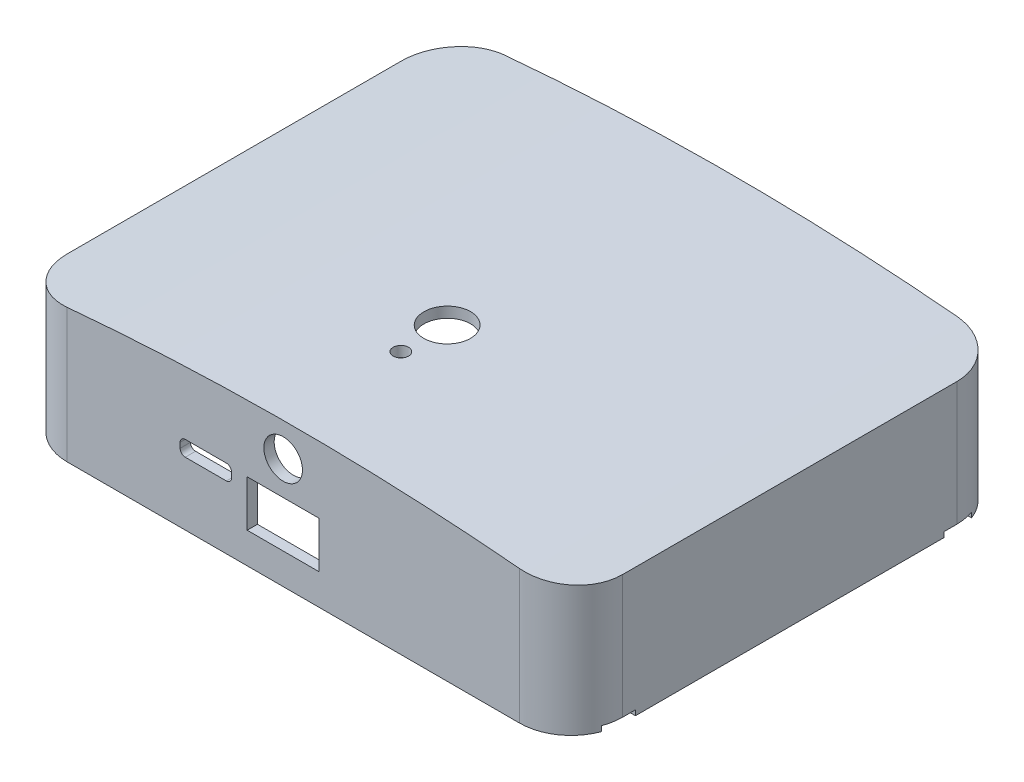
from build123d import *

# Parameters (mm, degrees)
BOSS_EXTRUDE5_DEPTH = 42
CUT_EXTRUDE6_DEPTH  = 95
BOSS_EXTRUDE8_DEPTH = 85
CUT_EXTRUDE7_DEPTH  = 85
SKETCH26_W          = 14
SKETCH26_H          = 9
SKETCH26_R          = 3.75
CUT_EXTRUDE9_DEPTH  = 15
BOSS_EXTRUDE9_DEPTH = 15
CUT_EXTRUDE11_DEPTH = 1
SKETCH30_R          = 1.4
CUT_EXTRUDE12_DEPTH = 15
CUT_EXTRUDE17_DEPTH = 3
SKETCH32_R          = 4.528419636
CUT_EXTRUDE18_DEPTH = 42
SKETCH33_R          = 1.5
CUT_EXTRUDE19_DEPTH = 42
CUT_EXTRUDE20_DEPTH = 3


with BuildPart() as part:
    # Sketch10 → Boss-Extrude5 (new body)
    with BuildSketch(Plane(origin=(0, 2, 0), x_dir=(1, 0, 0), z_dir=(0, 1, 0))):
        with BuildLine():
            Line((67.998956535, 10), (67.998956535, 75))
            ThreePointArc((67.998956535, 75), (65.070024347, 82.071067812), (57.998956535, 85))
            Line((57.998956535, 85), (-30.001043465, 85))
            ThreePointArc((-30.001043465, 85), (-37.072111277, 82.071067812), (-40.001043465, 75))
            Line((-40.001043465, 75), (-40.001043465, 10))
            ThreePointArc((-40.001043465, 10), (-37.072111277, 2.928932188), (-30.001043465, 0))
            Line((-30.001043465, 0), (57.998956535, 0))
            ThreePointArc((57.998956535, 0), (65.070024347, 2.928932188), (67.998956535, 10))
        make_face()
        with BuildLine():
            Line((57.998956535, 83), (-30.001043465, 83))
            ThreePointArc((-30.001043465, 83), (-35.657897714, 80.656854249), (-38.001043465, 75))
            Line((-38.001043465, 75), (-38.001043465, 10))
            ThreePointArc((-38.001043465, 10), (-35.657897714, 4.343145751), (-30.001043465, 2))
            Line((-30.001043465, 2), (57.998956535, 2))
            ThreePointArc((57.998956535, 2), (63.655810785, 4.343145751), (65.998956535, 10))
            Line((65.998956535, 10), (65.998956535, 75))
            ThreePointArc((65.998956535, 75), (63.655810785, 80.656854249), (57.998956535, 83))
        make_face(mode=Mode.SUBTRACT)
    extrude(amount=BOSS_EXTRUDE5_DEPTH)

    # Sketch22 → Cut-Extrude6 (cut)
    with BuildSketch(Plane.XY):
        with BuildLine():
            Line((67.998956535, 44), (67.998956535, 25))
            add(Edge.make_bspline(
                [(-40.001043465, 25), (13.998956535, 31.099161407), (67.998956535, 25)],
                knots=[0, 0, 0, 1, 1, 1], degree=2))
            Line((-40.001043465, 25), (-40.001043465, 44))
            Line((-40.001043465, 44), (-30.001043465, 44))
            Line((-30.001043465, 44), (57.998956535, 44))
            Line((57.998956535, 44), (67.998956535, 44))
        make_face()
    extrude(amount=-CUT_EXTRUDE6_DEPTH, mode=Mode.SUBTRACT)

    # Sketch20 → Boss-Extrude8 (add)
    with BuildSketch(Plane.XY):
        with BuildLine():
            Line((-40.001043465, 25), (-40.001043465, 27.029988546))
            add(Edge.make_bspline(
                [(67.998956535, 27.029988546), (13.998956535, 32.999215936), (-40.001043465, 27.029988546)],
                knots=[0, 0, 0, 1, 1, 1], degree=2))
            Line((67.998956535, 27.029988546), (67.998956535, 25))
            add(Edge.make_bspline(
                [(-40.001043465, 25), (13.998956535, 30.916770486), (67.998956535, 25)],
                knots=[0, 0, 0, 1, 1, 1], degree=2))
        make_face()
    extrude(amount=-BOSS_EXTRUDE8_DEPTH)

    # Sketch23 → Cut-Extrude7 (cut)
    with BuildSketch(Plane.XZ.offset(-2)):
        with BuildLine():
            Line((-40.001043465, -75), (-40.001043465, -85))
            Line((-40.001043465, -85), (-30.001043465, -85))
            ThreePointArc((-30.001043465, -85), (-37.072111277, -82.071067812), (-40.001043465, -75))
        make_face()
        with BuildLine():
            Line((57.998956535, -85), (67.998956535, -85))
            Line((67.998956535, -85), (67.998956535, -75))
            ThreePointArc((67.998956535, -75), (65.070024347, -82.071067812), (57.998956535, -85))
        make_face()
        with BuildLine():
            Line((67.998956535, -10), (67.998956535, 0))
            Line((67.998956535, 0), (57.998956535, 0))
            ThreePointArc((57.998956535, 0), (65.070024347, -2.928932188), (67.998956535, -10))
        make_face()
        with BuildLine():
            Line((-30.001043465, 0), (-40.001043465, 0))
            Line((-40.001043465, 0), (-40.001043465, -10))
            ThreePointArc((-40.001043465, -10), (-37.072111277, -2.928932188), (-30.001043465, 0))
        make_face()
    extrude(amount=-CUT_EXTRUDE7_DEPTH, mode=Mode.SUBTRACT)

    # Sketch26 → Cut-Extrude9 (cut)
    with BuildSketch(Plane.XY):
        with Locations((11.998956535, 12.5)):
            Rectangle(SKETCH26_W, SKETCH26_H)
        with Locations((11.998956535, 23.5)):
            Circle(SKETCH26_R)
    extrude(amount=-CUT_EXTRUDE9_DEPTH, mode=Mode.SUBTRACT)

    # Sketch28 → Boss-Extrude9 (add)
    with BuildSketch(Plane.XZ.offset(-2)):
        with BuildLine():
            Line((67.998956535, -75), (67.998956535, -72.5))
            Line((67.998956535, -72.5), (63.998956535, -72.5))
            ThreePointArc((63.998956535, -72.5), (60.998956535, -75.5), (63.998956535, -78.5))
            Line((63.998956535, -78.5), (67.366453533, -78.5))
            ThreePointArc((67.366453533, -78.5), (67.839560429, -76.778346145), (67.998956535, -75))
        make_face()
        with BuildLine():
            Line((-40.001043465, -10), (-40.001043465, -12.5))
            Line((-40.001043465, -12.5), (-36.001043465, -12.5))
            ThreePointArc((-36.001043465, -12.5), (-33.001043465, -9.5), (-36.001043465, -6.5))
            Line((-36.001043465, -6.5), (-39.368540462, -6.5))
            ThreePointArc((-39.368540462, -6.5), (-39.841647358, -8.221653855), (-40.001043465, -10))
        make_face()
        with BuildLine():
            Line((63.998956535, -12.5), (67.998956535, -12.5))
            Line((67.998956535, -12.5), (67.998956535, -10))
            ThreePointArc((67.998956535, -10), (67.839560429, -8.221653855), (67.366453533, -6.5))
            Line((67.366453533, -6.5), (63.998956535, -6.5))
            ThreePointArc((63.998956535, -6.5), (60.998956535, -9.5), (63.998956535, -12.5))
        make_face()
        with BuildLine():
            Line((-40.001043465, -72.5), (-40.001043465, -75))
            ThreePointArc((-40.001043465, -75), (-39.841647358, -76.778346145), (-39.368540462, -78.5))
            Line((-39.368540462, -78.5), (-36.001043465, -78.5))
            ThreePointArc((-36.001043465, -78.5), (-33.001043465, -75.5), (-36.001043465, -72.5))
            Line((-36.001043465, -72.5), (-40.001043465, -72.5))
        make_face()
    extrude(amount=-BOSS_EXTRUDE9_DEPTH)

    # Sketch29 → Cut-Extrude11 (cut)
    with BuildSketch(Plane.XZ.offset(-2)):
        with BuildLine():
            Line((67.998956535, -72.5), (67.998956535, -75))
            ThreePointArc((67.998956535, -75), (67.839560429, -76.778346145), (67.366453533, -78.5))
            Line((67.366453533, -78.5), (63.998956535, -78.5))
            ThreePointArc((63.998956535, -78.5), (60.998956535, -75.5), (63.998956535, -72.5))
            Line((63.998956535, -72.5), (67.998956535, -72.5))
        make_face()
        with BuildLine():
            Line((63.998956535, -12.5), (67.998956535, -12.5))
            Line((67.998956535, -12.5), (67.998956535, -10))
            ThreePointArc((67.998956535, -10), (67.839560429, -8.221653855), (67.366453533, -6.5))
            Line((67.366453533, -6.5), (63.998956535, -6.5))
            ThreePointArc((63.998956535, -6.5), (60.998956535, -9.5), (63.998956535, -12.5))
        make_face()
        with BuildLine():
            Line((-40.001043465, -12.5), (-40.001043465, -10))
            ThreePointArc((-40.001043465, -10), (-39.841647358, -8.221653855), (-39.368540462, -6.5))
            Line((-39.368540462, -6.5), (-36.001043465, -6.5))
            ThreePointArc((-36.001043465, -6.5), (-33.001043465, -9.5), (-36.001043465, -12.5))
            Line((-36.001043465, -12.5), (-40.001043465, -12.5))
        make_face()
        with BuildLine():
            Line((-39.368540462, -78.5), (-36.001043465, -78.5))
            ThreePointArc((-36.001043465, -78.5), (-33.001043465, -75.5), (-36.001043465, -72.5))
            Line((-36.001043465, -72.5), (-40.001043465, -72.5))
            Line((-40.001043465, -72.5), (-40.001043465, -75))
            ThreePointArc((-40.001043465, -75), (-39.841647358, -76.778346145), (-39.368540462, -78.5))
        make_face()
    extrude(amount=-CUT_EXTRUDE11_DEPTH, mode=Mode.SUBTRACT)

    # Sketch30 → Cut-Extrude12 (cut)
    with BuildSketch(Plane.XZ.offset(-3)):
        with Locations((-36.001043465, -9.5)):
            Circle(SKETCH30_R)
        with Locations((63.998956535, -9.5)):
            Circle(SKETCH30_R)
        with Locations((63.998956535, -75.5)):
            Circle(SKETCH30_R)
        with Locations((-36.001043465, -75.5)):
            Circle(SKETCH30_R)
    extrude(amount=-CUT_EXTRUDE12_DEPTH, mode=Mode.SUBTRACT)

    # Sketch31 → Cut-Extrude17 (cut)
    with BuildSketch(Plane.ZY.offset(40.001043465)):
        with BuildLine():
            Line((-63.5, 13), (-53.5, 13))
            ThreePointArc((-53.5, 13), (-52.792893219, 13.292893219), (-52.5, 14))
            Line((-52.5, 14), (-52.5, 19))
            ThreePointArc((-52.5, 19), (-52.792893219, 19.707106781), (-53.5, 20))
            Line((-53.5, 20), (-63.5, 20))
            ThreePointArc((-63.5, 20), (-64.207106781, 19.707106781), (-64.5, 19))
            Line((-64.5, 19), (-64.5, 14))
            ThreePointArc((-64.5, 14), (-64.207106781, 13.292893219), (-63.5, 13))
        make_face()
    extrude(amount=-CUT_EXTRUDE17_DEPTH, mode=Mode.SUBTRACT)

    # Sketch32 → Cut-Extrude18 (cut)
    with BuildSketch(Plane.XZ.offset(-2)):
        with Locations((11.884741139, -32)):
            Circle(SKETCH32_R)
    extrude(amount=-CUT_EXTRUDE18_DEPTH, mode=Mode.SUBTRACT)

    # Sketch33 → Cut-Extrude19 (cut)
    with BuildSketch(Plane.XZ.offset(-2)):
        with Locations((11.884741139, -23)):
            Circle(SKETCH33_R)
    extrude(amount=-CUT_EXTRUDE19_DEPTH, mode=Mode.SUBTRACT)

    # Sketch34 → Cut-Extrude20 (cut)
    with BuildSketch(Plane.XY):
        with BuildLine():
            Line((-7.038961127, 17.276986822), (0.961038873, 17.276986822))
            ThreePointArc((0.961038873, 17.276986822), (1.668145654, 16.984093603), (1.961038873, 16.276986822))
            Line((1.961038873, 16.276986822), (1.961038873, 15.276986822))
            ThreePointArc((1.961038873, 15.276986822), (1.668145654, 14.569880041), (0.961038873, 14.276986822))
            Line((0.961038873, 14.276986822), (-7.038961127, 14.276986822))
            ThreePointArc((-7.038961127, 14.276986822), (-7.746067908, 14.569880041), (-8.038961127, 15.276986822))
            Line((-8.038961127, 15.276986822), (-8.038961127, 16.276986822))
            ThreePointArc((-8.038961127, 16.276986822), (-7.746067908, 16.984093603), (-7.038961127, 17.276986822))
        make_face()
    extrude(amount=-CUT_EXTRUDE20_DEPTH, mode=Mode.SUBTRACT)


solid = part.part
